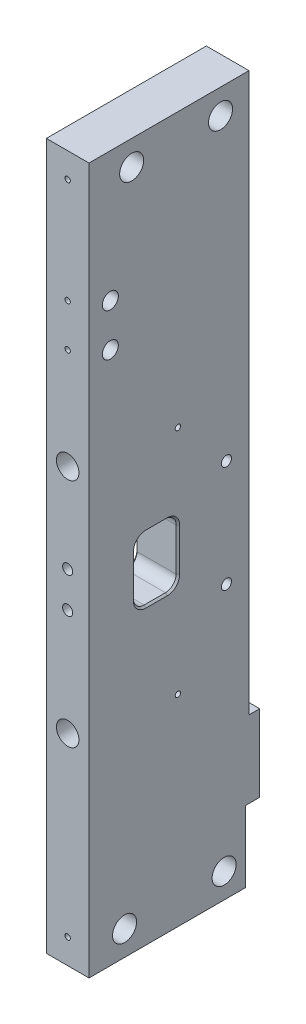
from build123d import *

# Parameters (mm, degrees)
SKETCH1_W                       = 48.000000106
SKETCH1_H                       = 198.5
EXTRUDE1_DEPTH                  = 12
SKETCH2_W                       = 3
SKETCH2_H                       = 156.9
EXTRUDE2_DEPTH                  = 13
SKETCH3_R                       = 3.3782
SKETCH3_R_2                     = 0.75
EXTRUDE3_DEPTH                  = 13
SKETCH4_W                       = 12
SKETCH4_H                       = 18
EXTRUDE4_DEPTH                  = 13
FILLET1_R                       = 3
CHAMFER1_SIZE                   = 0.5
EXTRUDE5_DEPTH                  = 20
F_4_40_TAPPED_HOLE1_D           = 2.8448
F_4_40_TAPPED_HOLE2_D           = 2.2606
F_4_40_TAPPED_HOLE2_DEPTH       = 12.6746
F_4_40_TAPPED_HOLE2_CBORE_D     = 2.8448
F_4_40_TAPPED_HOLE2_CBORE_DEPTH = 5.6896
F_4_40_TAPPED_HOLE2_TIP         = 0.679152758
F_1_4_20_TAPPED_HOLE1_D         = 6.35
SKETCH9_R                       = 0.75
EXTRUDE6_DEPTH                  = 8
SKETCH10_R                      = 0.75
EXTRUDE7_DEPTH                  = 8
SKETCH12_R                      = 0.75
EXTRUDE8_DEPTH                  = 8
SKETCH13_R                      = 2.25
CUT_EXTRUDE1_DEPTH              = 13.0000001
SKETCH14_R                      = 0.75
CUT_EXTRUDE2_DEPTH              = 6


with BuildPart() as part:
    # Sketch1 → Extrude1 (new body)
    with BuildSketch(Plane(origin=(0, 0, 0), x_dir=(0, 0, -1), z_dir=(1, 0, 0))):
        with Locations((-24.000000053, 99.25)):
            Rectangle(SKETCH1_W, SKETCH1_H)
    extrude(amount=EXTRUDE1_DEPTH)

    # Sketch2 → Extrude2 (cut, through all)
    with BuildSketch(Plane(origin=(12, 0, 0), x_dir=(0, 0, -1), z_dir=(1, 0, 0))):
        with Locations((-1.5, 120.05)):
            Rectangle(SKETCH2_W, SKETCH2_H)
    extrude(amount=-EXTRUDE2_DEPTH, mode=Mode.SUBTRACT)

    # Sketch3 → Extrude3 (cut, through all)
    with BuildSketch(Plane(origin=(12, 0, 0), x_dir=(0, 0, -1), z_dir=(1, 0, 0))):
        with Locations((-36.000000106, 191.5)):
            Circle(SKETCH3_R)
        with Locations((-11.000000106, 191.5)):
            Circle(SKETCH3_R)
        with Locations((-38.000000106, 7)):
            Circle(SKETCH3_R)
        with Locations((-10.000000106, 7)):
            Circle(SKETCH3_R)
        with Locations((-23.000000106, 56.6)):
            Circle(SKETCH3_R_2)
        with Locations((-23.000000106, 121.6)):
            Circle(SKETCH3_R_2)
    extrude(amount=-EXTRUDE3_DEPTH, mode=Mode.SUBTRACT)

    # Sketch4 → Extrude4 (cut, through all)
    with BuildSketch(Plane(origin=(12, 0, 0), x_dir=(0, 0, -1), z_dir=(1, 0, 0))):
        with Locations((-29.000000106, 91.6)):
            Rectangle(SKETCH4_W, SKETCH4_H)
    extrude(amount=-EXTRUDE4_DEPTH, mode=Mode.SUBTRACT)

    # Fillet1
    fillet1_edges = [part.edges().sort_by_distance(p)[0] for p in [
        (6, 82.6, 35.000000106),
        (6, 100.6, 35.000000106),
        (6, 100.6, 23.000000106),
        (6, 82.6, 23.000000106),
    ]]
    fillet(fillet1_edges, radius=FILLET1_R)

    # Chamfer1
    chamfer1_edges = [part.edges().sort_by_distance(p)[0] for p in [
        (12, 91.6, 35.000000106),
        (0, 91.6, 35.000000106),
        (12, 100.6, 29.000000106),
        (0, 100.6, 29.000000106),
        (12, 91.6, 23.000000106),
        (0, 91.6, 23.000000106),
        (12, 82.6, 29.000000106),
        (0, 82.6, 29.000000106),
        (12, 99.721320344, 34.12132045),
        (0, 99.721320344, 34.12132045),
        (12, 99.721320344, 23.878679762),
        (0, 99.721320344, 23.878679762),
        (12, 83.478679656, 23.878679762),
        (0, 83.478679656, 23.878679762),
        (12, 83.478679656, 34.12132045),
        (0, 83.478679656, 34.12132045),
    ]]
    chamfer(chamfer1_edges, length=CHAMFER1_SIZE)

    # Sketch5 → Extrude5 (cut)
    with BuildSketch(Plane.XZ):
        Polygon((0, 0), (4, 0), (0, 4), align=None)
    extrude5 = extrude(amount=-EXTRUDE5_DEPTH, mode=Mode.SUBTRACT)

    # Mirror1: Extrude5 across plane
    add(extrude5.mirror(Plane(origin=(6, 0, 0), x_dir=(0, 0, 1), z_dir=(1, 0, 0))), mode=Mode.SUBTRACT)

    # #4-40 Tapped Hole1 (through all)
    with Locations(Plane(origin=(12, 106.6, 9.35), x_dir=(0, 0, 1), z_dir=(1, 0, 0))):
        with Locations((0, 0), (0, 30)):
            Hole(F_4_40_TAPPED_HOLE1_D / 2)

    # #4-40 Tapped Hole2
    with Locations(Plane(origin=(6, 96.6, 48.000000106), x_dir=(1, 0, 0), z_dir=(0, 0, 1))):
        with Locations((0, 0), (0, -10)):
            CounterBoreHole(F_4_40_TAPPED_HOLE2_D / 2, F_4_40_TAPPED_HOLE2_CBORE_D / 2, F_4_40_TAPPED_HOLE2_CBORE_DEPTH, depth=F_4_40_TAPPED_HOLE2_DEPTH)
            with Locations((0, 0, -(F_4_40_TAPPED_HOLE2_DEPTH + F_4_40_TAPPED_HOLE2_TIP / 2))):  # 118° drill point
                Cone(0, F_4_40_TAPPED_HOLE2_D / 2, F_4_40_TAPPED_HOLE2_TIP, mode=Mode.SUBTRACT)

    # 1/4-20 Tapped Hole1 (through all)
    with Locations(Plane(origin=(6, 121.6, 48.000000106), x_dir=(1, 0, 0), z_dir=(0, 0, 1))):
        with Locations((0, 0), (0, -65)):
            Hole(F_1_4_20_TAPPED_HOLE1_D / 2)

    # Sketch9 → Extrude6 (cut)
    with BuildSketch(Plane.XY.offset(48.000000106)):
        with Locations((6, 7)):
            Circle(SKETCH9_R)
        with Locations((6, 191.5)):
            Circle(SKETCH9_R)
    extrude(amount=-EXTRUDE6_DEPTH, mode=Mode.SUBTRACT)

    # Sketch10 → Extrude7 (cut)
    with BuildSketch(Plane(origin=(0, 0, 3), x_dir=(-1, 0, 0), z_dir=(0, 0, -1))):
        with Locations(Location((-6, 191.5, 0), (0, 0, 180))):  # turned: the seam where the file's is
            Circle(SKETCH10_R)
    extrude(amount=-EXTRUDE7_DEPTH, mode=Mode.SUBTRACT)

    # Sketch12 → Extrude8 (cut)
    with BuildSketch(Plane(origin=(0, 0, 0), x_dir=(-1, 0, 0), z_dir=(0, 0, -1))):
        with Locations(Location((-6, 7, 0), (0, 0, 180))):  # turned: the seam where the file's is
            Circle(SKETCH12_R)
    extrude(amount=-EXTRUDE8_DEPTH, mode=Mode.SUBTRACT)

    # Sketch13 → Cut-Extrude1 (cut, through all)
    with BuildSketch(Plane(origin=(12, 0, 0), x_dir=(0, 0, -1), z_dir=(1, 0, 0))):
        with Locations((-42.000000106, 162)):
            Circle(SKETCH13_R)
        with Locations((-42.000000106, 150)):
            Circle(SKETCH13_R)
    extrude(amount=-CUT_EXTRUDE1_DEPTH, mode=Mode.SUBTRACT)

    # Sketch14 → Cut-Extrude2 (cut)
    with BuildSketch(Plane.XY.offset(48.000000106)):
        with Locations((6, 162)):
            Circle(SKETCH14_R)
        with Locations((6, 150)):
            Circle(SKETCH14_R)
    extrude(amount=-CUT_EXTRUDE2_DEPTH, mode=Mode.SUBTRACT)


solid = part.part
